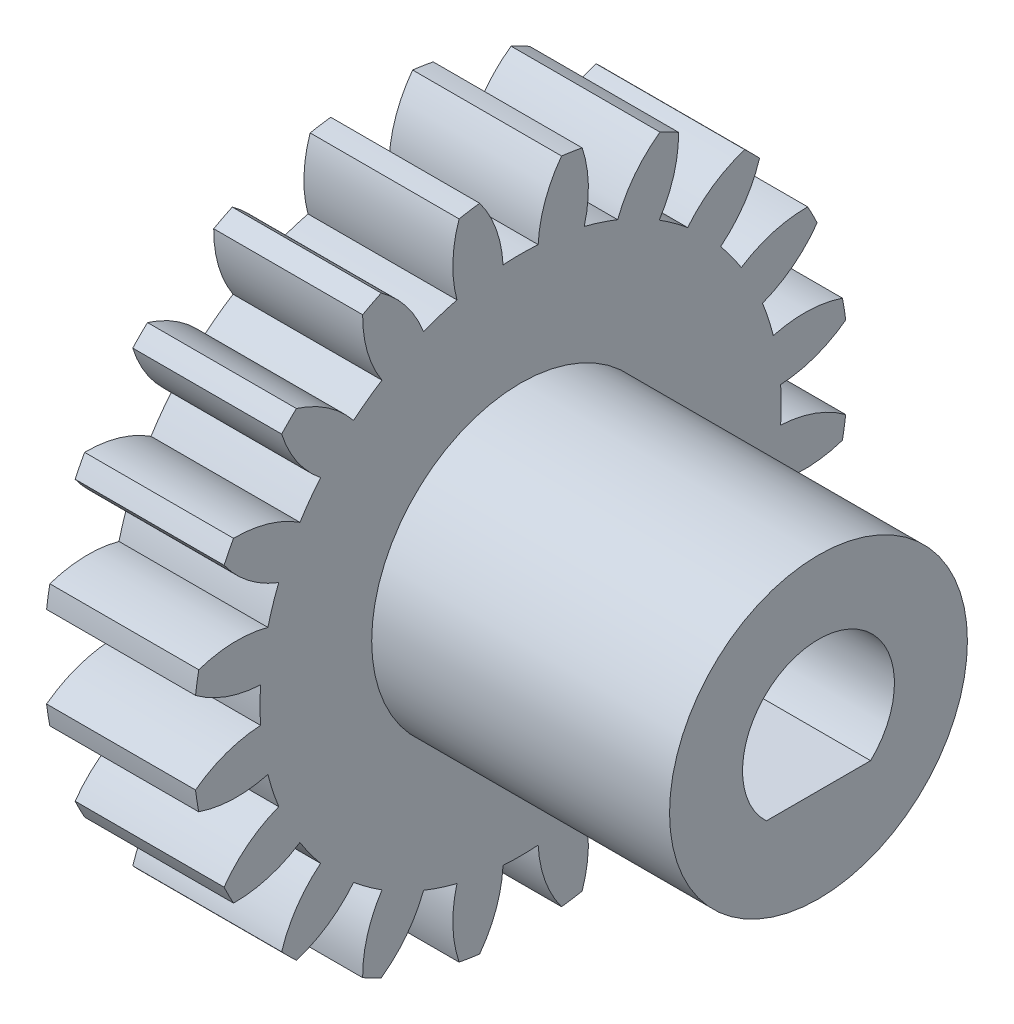
from build123d import *

# Parameters (mm, degrees)
BASPROSKE_W              = 5
BASPROSKE_H              = 11
TOOTHCUT_DEPTH           = 17.340134638
TEETHCUTS_COUNT          = 20
TEETHCUTS_ANGLE          = 342
BORSKE_R                 = 2.5
BORE_DEPTH               = 50.0000508
SKETCH1_R                = 5
BOSS_EXTRUDE2_DEPTH      = 10
BOSS_EXTRUDE2_DEPTH_BACK = 5
CUT_EXTRUDE1_DEPTH       = 22.522623175


with BuildPart() as part:
    # BasProSke → Base-Revolve (revolve)
    with BuildSketch(Plane(origin=(0, 0, 0), x_dir=(1, 0, 0), z_dir=(0, 1, 0)), mode=Mode.PRIVATE) as base_revolve_sk:
        with Locations((2.5, 5.5)):
            Rectangle(BASPROSKE_W, BASPROSKE_H)
    revolve(base_revolve_sk.sketch.rotate(Axis((-10, 0, 0), (1, 0, 0)), 180), axis=Axis((-10, 0, 0), (1, 0, 0)))

    # TooCutSke → ToothCut (cut, through all)
    with BuildSketch(Plane(origin=(0, 0, 0), x_dir=(0, 0, -1), z_dir=(1, 0, 0))):
        with BuildLine():
            ThreePointArc((0.589353609, 8.729127295), (0, 8.749), (-0.589353609, 8.729127295))
            ThreePointArc((-0.589353609, 8.729127295), (-0.82475631, 9.893403384), (-1.391689312, 10.937213814))
            ThreePointArc((-1.391689312, 10.937213814), (0, 11.0254), (1.391689312, 10.937213814))
            ThreePointArc((1.391689312, 10.937213814), (0.82475631, 9.893403384), (0.589353609, 8.729127295))
        make_face()
    toothcut = extrude(amount=TOOTHCUT_DEPTH, mode=Mode.SUBTRACT)

    # TeethCuts: ToothCut ×20 about axis
    teethcuts_axis = Axis((-10, 0, 0), (1, 0, 0))
    for i in range(1, TEETHCUTS_COUNT):
        add(toothcut.rotate(teethcuts_axis, i * TEETHCUTS_ANGLE / (TEETHCUTS_COUNT - 1)), mode=Mode.SUBTRACT)

    # BorSke → Bore (cut, symmetric)
    with BuildSketch(Plane(origin=(0, 0, 0), x_dir=(0, 0, -1), z_dir=(1, 0, 0))):
        with Locations(Location((0, 0, 0), (0, 0, 180))):
            Circle(BORSKE_R)
    extrude(amount=BORE_DEPTH, both=True, mode=Mode.SUBTRACT)

    # Sketch1 → Boss-Extrude2 (add, two sides)
    with BuildSketch(Plane(origin=(5, 0, 0), x_dir=(0, 0, -1), z_dir=(1, 0, 0))) as boss_extrude2_sk:
        Circle(SKETCH1_R)
    extrude(amount=BOSS_EXTRUDE2_DEPTH)
    extrude(boss_extrude2_sk.sketch, amount=-BOSS_EXTRUDE2_DEPTH_BACK)

    # Sketch2 → Cut-Extrude1 (cut, through all)
    with BuildSketch(Plane(origin=(15, 0, 0), x_dir=(0, 0, -1), z_dir=(1, 0, 0))):
        with BuildLine():
            ThreePointArc((2.55, 0), (-1.009950494, 2.341473895), (-1.75, -1.854723699))
            Line((-1.75, -1.854723699), (1.75, -1.854723699))
            ThreePointArc((1.75, -1.854723699), (2.341473895, -1.009950494), (2.55, 0))
        make_face()
    extrude(amount=-CUT_EXTRUDE1_DEPTH, mode=Mode.SUBTRACT)


solid = part.part
